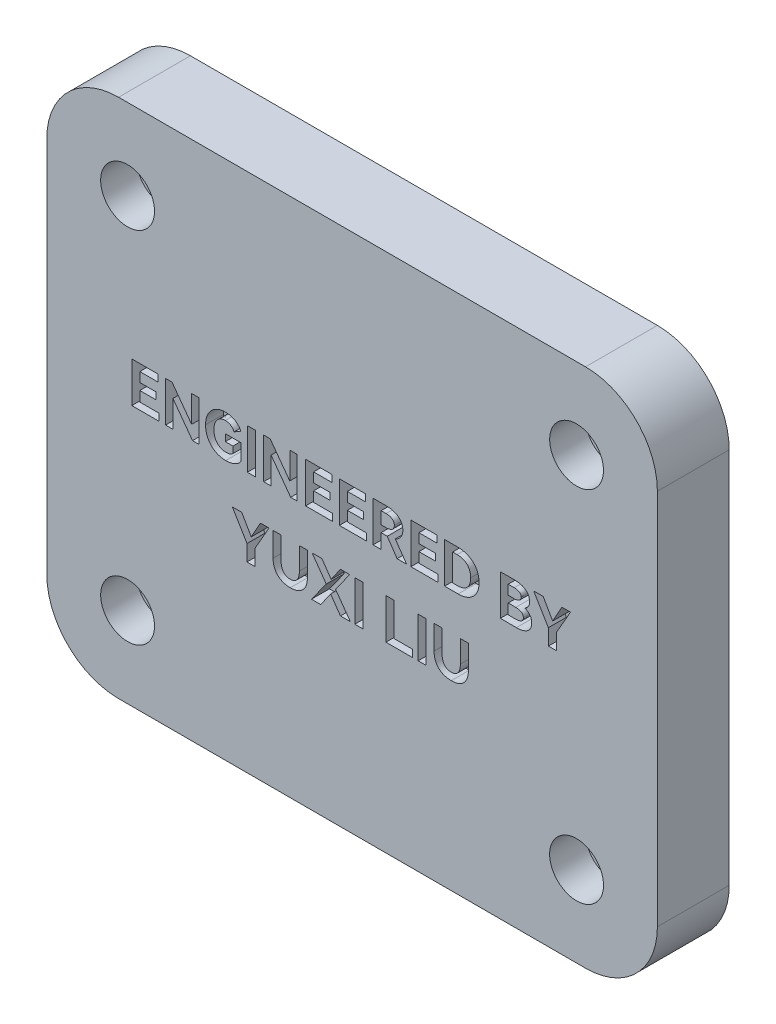
from build123d import *

# Parameters (mm, degrees)
SKETCH1_W           = 68
SKETCH1_H           = 58
BOSS_EXTRUDE1_DEPTH = 8
SKETCH2_R           = 1.6
CUT_EXTRUDE1_DEPTH  = 90.732937097
SKETCH3_R           = 3
CUT_EXTRUDE2_DEPTH  = 4
FILLET1_R           = 8
SKETCH4_W           = 0.89110672
SKETCH4_H           = 4.5
SKETCH4_W_2         = 0.891106719
CUT_EXTRUDE3_DEPTH  = 2


with BuildPart() as part:
    # Sketch1 → Boss-Extrude1 (new body)
    with BuildSketch(Plane.XY):
        with Locations((34, 29)):
            Rectangle(SKETCH1_W, SKETCH1_H)
    extrude(amount=BOSS_EXTRUDE1_DEPTH)

    # Sketch2 → Cut-Extrude1 (cut, through all)
    with BuildSketch(Plane.XY.offset(8)):
        with Locations((9, 49)):
            Circle(SKETCH2_R)
        with Locations(Location((59, 49, 0), (0, 0, 180))):
            Circle(SKETCH2_R)
        with Locations((59, 9)):
            Circle(SKETCH2_R)
        with Locations(Location((9, 9, 0), (0, 0, 180))):
            Circle(SKETCH2_R)
    extrude(amount=-CUT_EXTRUDE1_DEPTH, mode=Mode.SUBTRACT)

    # Sketch3 → Cut-Extrude2 (cut)
    with BuildSketch(Plane.XY.offset(8)):
        with Locations((9, 49)):
            Circle(SKETCH3_R)
        with Locations(Location((59, 49, 0), (0, 0, 180))):
            Circle(SKETCH3_R)
        with Locations((59, 9)):
            Circle(SKETCH3_R)
        with Locations(Location((9, 9, 0), (0, 0, 180))):
            Circle(SKETCH3_R)
    extrude(amount=-CUT_EXTRUDE2_DEPTH, mode=Mode.SUBTRACT)

    # Fillet1
    fillet1_edges = [part.edges().sort_by_distance(p)[0] for p in [
        (0, 58, 4),
        (68, 58, 4),
        (68, 0, 4),
        (0, 0, 4),
    ]]
    fillet(fillet1_edges, radius=FILLET1_R)

    # Sketch4 → Cut-Extrude3 (cut)
    with BuildSketch(Plane.XY.offset(8)):
        Polygon((12.190019763, 30.899604743), (10.364229249, 30.899604743), (10.364229249, 29.78083004), (12.472826087, 29.78083004), (12.472826087, 29), (9.47312253, 29), (9.47312253, 33.5), (12.405237154, 33.5), (12.405237154, 32.725395257), (10.364229249, 32.725395257), (10.364229249, 31.66798419), (12.190019763, 31.66798419), align=None)
        Polygon((13.949110672, 33.5), (16.131521739, 30.5243083), (16.131521739, 33.5), (16.961264822, 33.5), (16.961264822, 29), (16.235573123, 29), (14.047826087, 31.981027668), (14.047826087, 29), (13.229644269, 29), (13.229644269, 33.5), align=None)
        with BuildLine():
            Line((19.88270751, 30.727075099), (19.88270751, 31.495454545))
            Line((19.88270751, 31.495454545), (21.603557312, 31.495454545))
            Line((21.603557312, 31.495454545), (21.603557312, 29.663438735))
            add(Edge.make_bspline(
                [(21.603557312, 29.663438735), (21.585447013, 29.635459828), (21.549129791, 29.579352739), (21.483778407, 29.501847101), (21.411893283, 29.428092613), (21.332367461, 29.358267831), (21.244525097, 29.293515303), (21.14966514, 29.231717851), (21.04577871, 29.176459685), (20.936457937, 29.123641364), (20.82075793, 29.078241641), (20.702085581, 29.036753427), (20.579431167, 29.003536577), (20.454429545, 28.974424008), (20.325956051, 28.953875328), (20.195233451, 28.93716636), (20.061277186, 28.92868716), (19.971056671, 28.927026331), (19.925395257, 28.926185771)],
                knots=[0, 0, 0, 0, 0.837760271, 1.679990217, 2.544929539, 3.427533874, 4.338910806, 5.288456801, 6.272945858, 7.297089327, 8.341320962, 9.397943387, 10.45827055, 11.53659533, 12.625366476, 13.72988631, 14.851075027, 16, 16, 16, 16], degree=3))
            add(Edge.make_bspline(
                [(19.925395257, 28.926185771), (19.871409128, 28.926938661), (19.764725815, 28.928426467), (19.607045736, 28.943308769), (19.453811488, 28.966301087), (19.305057423, 28.997880887), (19.161195377, 29.040336188), (19.021700147, 29.090670993), (18.886659717, 29.150475949), (18.757238472, 29.219742062), (18.633660795, 29.297431544), (18.515757924, 29.381345642), (18.406339853, 29.474800779), (18.303104708, 29.573882698), (18.207380985, 29.680793635), (18.117984879, 29.794316297), (18.03776203, 29.916844827), (17.962681677, 30.044628298), (17.895738896, 30.178677193), (17.83950323, 30.318868234), (17.789638289, 30.463067224), (17.751500793, 30.612632974), (17.719587191, 30.766527349), (17.697892321, 30.925492423), (17.684083877, 31.089378631), (17.682448163, 31.200169384), (17.681620553, 31.256225296)],
                knots=[0, 0, 0, 0, 1.069561296, 2.113586308, 3.135478133, 4.139054237, 5.124324395, 6.105523171, 7.075971085, 8.048372863, 9.011682409, 9.96706009, 10.913291369, 11.860525061, 12.800627657, 13.754830667, 14.721001889, 15.700334832, 16.690775213, 17.686757511, 18.691776819, 19.711978727, 20.743098853, 21.804839495, 22.889332181, 24, 24, 24, 24], degree=3))
            add(Edge.make_bspline(
                [(17.681620553, 31.256225296), (17.682338975, 31.312882599), (17.683755609, 31.424603387), (17.699035365, 31.589284548), (17.720455292, 31.749232262), (17.752842427, 31.903885675), (17.793450865, 32.054112689), (17.8446463, 32.198732073), (17.902836931, 32.339200919), (17.971957173, 32.473275494), (18.047737827, 32.60194538), (18.131602606, 32.722934999), (18.221747917, 32.83657806), (18.318951419, 32.942646704), (18.422918612, 33.041359504), (18.53383921, 33.132497567), (18.651142017, 33.216118138), (18.774939167, 33.291566893), (18.903742404, 33.359283907), (19.037031444, 33.417688096), (19.173607483, 33.467735011), (19.31340981, 33.509044483), (19.457164658, 33.539563432), (19.603705448, 33.563163425), (19.754094276, 33.57660903), (19.855409131, 33.578295896), (19.906719368, 33.579150198)],
                knots=[0, 0, 0, 0, 1.131159616, 2.230498763, 3.300513467, 4.352457935, 5.383673727, 6.405979992, 7.414253141, 8.417735126, 9.415806143, 10.394568984, 11.355223429, 12.310609564, 13.265408537, 14.21597661, 15.175353225, 16.139940019, 17.109148635, 18.079351229, 19.043919855, 20.012477316, 20.987904129, 21.976802477, 22.975365016, 24, 24, 24, 24], degree=3))
            add(Edge.make_bspline(
                [(19.906719368, 33.579150198), (19.957741945, 33.578353381), (20.058186994, 33.576784736), (20.206014044, 33.56269204), (20.349116485, 33.542108163), (20.486521983, 33.51059684), (20.619186239, 33.471550943), (20.74663359, 33.423253317), (20.869459761, 33.366830499), (20.985491776, 33.300373735), (21.095462155, 33.229405951), (21.196029117, 33.151779924), (21.287574526, 33.06966007), (21.369329282, 32.982214095), (21.443108414, 32.890611067), (21.505887802, 32.793010224), (21.561401855, 32.691536584), (21.589480018, 32.619905248), (21.603557312, 32.583992095)],
                knots=[0, 0, 0, 0, 1.17016001, 2.303622935, 3.403856837, 4.484454622, 5.534447873, 6.5739282, 7.608391433, 8.631549699, 9.638764269, 10.608576157, 11.542682489, 12.456771363, 13.352074797, 14.236699835, 15.115950192, 16, 16, 16, 16], degree=3))
            Line((21.603557312, 32.583992095), (20.866304348, 32.159782609))
            add(Edge.make_bspline(
                [(20.866304348, 32.159782609), (20.842751165, 32.205375626), (20.796433867, 32.295034225), (20.70430848, 32.414031084), (20.59980661, 32.519548247), (20.480179247, 32.608417335), (20.34792225, 32.680633245), (20.202752338, 32.730888687), (20.046600568, 32.763410013), (19.93831196, 32.766497585), (19.88270751, 32.768083004)],
                knots=[0, 0, 0, 0, 1.004386668, 1.97512485, 2.936911434, 3.908797535, 4.886714011, 5.879478124, 6.91114628, 8, 8, 8, 8], degree=3))
            add(Edge.make_bspline(
                [(19.88270751, 32.768083004), (19.82353494, 32.765969904), (19.707391906, 32.761822343), (19.538117607, 32.72580976), (19.378094463, 32.667702216), (19.228365362, 32.586329145), (19.090822965, 32.483953111), (18.968540785, 32.360016776), (18.861419855, 32.216746268), (18.77083859, 32.054408901), (18.698831788, 31.875119675), (18.647768576, 31.680944394), (18.615912822, 31.473082126), (18.612059983, 31.329861795), (18.610079051, 31.256225296)],
                knots=[0, 0, 0, 0, 0.961041044, 1.886316962, 2.799516737, 3.720263746, 4.646492936, 5.576775119, 6.540591128, 7.546013389, 8.590342615, 9.672792099, 10.803469879, 12, 12, 12, 12], degree=3))
            add(Edge.make_bspline(
                [(18.610079051, 31.256225296), (18.610572534, 31.217969109), (18.611545305, 31.142557056), (18.619810833, 31.031256469), (18.632806593, 30.923738881), (18.6519616, 30.820287498), (18.674386898, 30.720186329), (18.704260011, 30.624568211), (18.737628755, 30.532073415), (18.777997727, 30.444496325), (18.82209492, 30.360779922), (18.871405886, 30.282203188), (18.924582366, 30.208287375), (18.982466557, 30.13949658), (19.04521297, 30.076553016), (19.110919789, 30.016989469), (19.18259776, 29.963952998), (19.257935712, 29.915047998), (19.337111424, 29.871258564), (19.419873723, 29.834019936), (19.505860488, 29.802778081), (19.594747428, 29.777208556), (19.68670906, 29.75629344), (19.781899753, 29.742672087), (19.88014108, 29.733112154), (19.94671496, 29.732319602), (19.980533597, 29.731916996)],
                knots=[0, 0, 0, 0, 1.190036652, 2.345845502, 3.470321741, 4.557532515, 5.617930628, 6.659430926, 7.671944366, 8.674877908, 9.656813806, 10.613877645, 11.558417442, 12.487751382, 13.407286364, 14.321766241, 15.244025914, 16.177742668, 17.114733078, 18.055844735, 18.998220842, 19.958478747, 20.931801387, 21.929590883, 22.948259987, 24, 24, 24, 24], degree=3))
            add(Edge.make_bspline(
                [(19.980533597, 29.731916996), (20.019402652, 29.732790956), (20.095270605, 29.734496826), (20.205904828, 29.747189297), (20.310095806, 29.767344326), (20.40796079, 29.795711916), (20.498879894, 29.833070159), (20.583053032, 29.878926817), (20.661599178, 29.932094373), (20.707905717, 29.974688356), (20.731126482, 29.996047431)],
                knots=[0, 0, 0, 0, 1.142493035, 2.230015796, 3.269182953, 4.259205674, 5.220542896, 6.152556429, 7.073585425, 8, 8, 8, 8], degree=3))
            Line((20.731126482, 29.996047431), (20.731126482, 30.727075099))
            Line((20.731126482, 30.727075099), (19.88270751, 30.727075099))
        make_face()
        with Locations((22.781916996, 31.25)):
            Rectangle(SKETCH4_W, SKETCH4_H)
        Polygon((24.877173913, 33.5), (27.05958498, 30.5243083), (27.05958498, 33.5), (27.889328063, 33.5), (27.889328063, 29), (27.163636364, 29), (24.975889328, 31.981027668), (24.975889328, 29), (24.15770751, 29), (24.15770751, 33.5), align=None)
        Polygon((31.541798419, 30.899604743), (29.716007905, 30.899604743), (29.716007905, 29.78083004), (31.824604743, 29.78083004), (31.824604743, 29), (28.824901186, 29), (28.824901186, 33.5), (31.75701581, 33.5), (31.75701581, 32.725395257), (29.716007905, 32.725395257), (29.716007905, 31.66798419), (31.541798419, 31.66798419), align=None)
        Polygon((35.298320158, 30.899604743), (33.472529644, 30.899604743), (33.472529644, 29.78083004), (35.581126482, 29.78083004), (35.581126482, 29), (32.581422925, 29), (32.581422925, 33.5), (35.513537549, 33.5), (35.513537549, 32.725395257), (33.472529644, 32.725395257), (33.472529644, 31.66798419), (35.298320158, 31.66798419), align=None)
        with BuildLine():
            Line((40.075790514, 29), (39.01215415, 29.006225296))
            Line((39.01215415, 29.006225296), (37.918280632, 30.623023715))
            Line((37.918280632, 30.623023715), (37.880928854, 30.623023715))
            Line((37.880928854, 30.623023715), (37.229051383, 30.623023715))
            Line((37.229051383, 30.623023715), (37.229051383, 29))
            Line((37.229051383, 29), (36.337944664, 29))
            Line((36.337944664, 29), (36.337944664, 33.5))
            Line((36.337944664, 33.5), (37.893379447, 33.5))
            add(Edge.make_bspline(
                [(37.893379447, 33.5), (37.936679816, 33.499606859), (38.022189633, 33.498830482), (38.148223538, 33.489103588), (38.270605298, 33.476411814), (38.388844446, 33.456982396), (38.502579159, 33.430682165), (38.612748583, 33.400952622), (38.718540022, 33.364053528), (38.820654082, 33.322794195), (38.917544489, 33.275375392), (39.009289511, 33.224136509), (39.094941597, 33.167666163), (39.175456042, 33.107464879), (39.249551041, 33.041139713), (39.31768814, 32.970193591), (39.380687969, 32.894914748), (39.437214416, 32.815064858), (39.488192475, 32.731495571), (39.5318286, 32.644278992), (39.567841286, 32.553813054), (39.599877896, 32.461632198), (39.622436751, 32.365559348), (39.639601857, 32.267013963), (39.649360955, 32.165017603), (39.650833536, 32.096066959), (39.651581028, 32.061067194)],
                knots=[0, 0, 0, 0, 1.2200695, 2.409400225, 3.560858665, 4.687156797, 5.783684645, 6.849872993, 7.90145962, 8.939416468, 9.952046838, 10.939655477, 11.899012187, 12.841448216, 13.770493987, 14.69818634, 15.611737774, 16.534412784, 17.452879405, 18.368300956, 19.279020852, 20.195813937, 21.115799313, 22.056678637, 23.013558267, 24, 24, 24, 24], degree=3))
            add(Edge.make_bspline(
                [(39.651581028, 32.061067194), (39.65092733, 32.025760747), (39.649633377, 31.955873799), (39.638478491, 31.853110903), (39.621840227, 31.753469143), (39.597677141, 31.657149432), (39.566658974, 31.563717426), (39.528331327, 31.473570348), (39.482732353, 31.387251201), (39.430971496, 31.304370934), (39.373565843, 31.225129524), (39.308996587, 31.151336334), (39.239497974, 31.081783069), (39.164828487, 31.016713468), (39.084173188, 30.956779037), (38.99775389, 30.901963695), (38.906318748, 30.850729656), (38.84193412, 30.821759294), (38.809387352, 30.807114625)],
                knots=[0, 0, 0, 0, 1.054662233, 2.087639297, 3.085144338, 4.071218206, 5.051586526, 6.023918905, 6.994636113, 7.965474552, 8.941672438, 9.914932327, 10.892013905, 11.877769453, 12.871610298, 13.891324161, 14.934053283, 16, 16, 16, 16], degree=3))
            Line((38.809387352, 30.807114625), (40.075790514, 29))
        make_face()
        with BuildLine():
            Line((37.229051383, 32.743181818), (37.229051383, 31.378952569))
            Line((37.229051383, 31.378952569), (37.788438735, 31.378952569))
            add(Edge.make_bspline(
                [(37.788438735, 31.378952569), (37.820471735, 31.379448719), (37.883454677, 31.380424243), (37.975831558, 31.38856891), (38.064386311, 31.401784315), (38.148381445, 31.420521454), (38.228659971, 31.443329035), (38.303863977, 31.47305816), (38.375903199, 31.506754044), (38.443100893, 31.546411806), (38.50428215, 31.591565494), (38.558908306, 31.641318134), (38.603260091, 31.698489924), (38.641327413, 31.759785685), (38.6697824, 31.827704016), (38.690241884, 31.900559244), (38.701645259, 31.979191825), (38.703491999, 32.033166104), (38.70444664, 32.061067194)],
                knots=[0, 0, 0, 0, 1.193392064, 2.34643473, 3.452436324, 4.527106391, 5.551260628, 6.558417018, 7.536691432, 8.512280761, 9.460022067, 10.366574529, 11.254978474, 12.147219442, 13.047898509, 13.988597637, 14.960239605, 16, 16, 16, 16], degree=3))
            add(Edge.make_bspline(
                [(38.70444664, 32.061067194), (38.703456022, 32.089256557), (38.701528799, 32.144098255), (38.690564314, 32.223723151), (38.669376188, 32.297119875), (38.642492053, 32.365630905), (38.605126099, 32.427469757), (38.560631857, 32.484014282), (38.507287555, 32.534188856), (38.446613864, 32.578386105), (38.379925703, 32.617202837), (38.308514443, 32.651078974), (38.23265121, 32.679631423), (38.152208078, 32.702340284), (38.067747483, 32.721637801), (37.978402463, 32.733217295), (37.884950046, 32.741829667), (37.821069379, 32.742724654), (37.788438735, 32.743181818)],
                knots=[0, 0, 0, 0, 1.047934578, 2.038730344, 2.976872647, 3.881028202, 4.765166578, 5.651155837, 6.547222764, 7.476984859, 8.434839262, 9.410454722, 10.41093961, 11.4428885, 12.51463761, 13.626944928, 14.787828634, 16, 16, 16, 16], degree=3))
            Line((37.788438735, 32.743181818), (37.229051383, 32.743181818))
        make_face(mode=Mode.SUBTRACT)
        Polygon((43.266699605, 30.899604743), (41.440909091, 30.899604743), (41.440909091, 29.78083004), (43.549505929, 29.78083004), (43.549505929, 29), (40.549802372, 29), (40.549802372, 33.5), (43.481916996, 33.5), (43.481916996, 32.725395257), (41.440909091, 32.725395257), (41.440909091, 31.66798419), (43.266699605, 31.66798419), align=None)
        with BuildLine():
            add(Edge.make_bspline(
                [(45.806620553, 33.5), (45.860893251, 33.499100468), (45.96809906, 33.497323608), (46.126632921, 33.484576792), (46.281277371, 33.464039749), (46.432260393, 33.435960293), (46.579373829, 33.398700329), (46.721799539, 33.351740501), (46.8612025, 33.29882251), (46.995959883, 33.236487667), (47.125465595, 33.166848738), (47.247827345, 33.088751083), (47.363929083, 33.004465251), (47.472721689, 32.911664394), (47.574064805, 32.810907206), (47.668893169, 32.702994195), (47.755883775, 32.587091182), (47.836096765, 32.464272003), (47.908335844, 32.334673006), (47.970235608, 32.198163622), (48.024020375, 32.056355081), (48.067969231, 31.908133062), (48.100137771, 31.753295405), (48.123993555, 31.592960711), (48.140065557, 31.426709117), (48.141344392, 31.313773753), (48.141996047, 31.256225296)],
                knots=[0, 0, 0, 0, 1.071711807, 2.116971104, 3.138652708, 4.151338474, 5.148077585, 6.132969995, 7.111438821, 8.091097786, 9.062906638, 10.012978114, 10.955571233, 11.894065112, 12.833745052, 13.775465164, 14.728525936, 15.69302499, 16.670460021, 17.655439419, 18.650320097, 19.6635641, 20.704963763, 21.770502017, 22.863915051, 24, 24, 24, 24], degree=3))
            add(Edge.make_bspline(
                [(48.141996047, 31.256225296), (48.141334489, 31.198677443), (48.140032827, 31.085447948), (48.124036295, 30.918895329), (48.100257585, 30.758536558), (48.067740684, 30.603776154), (48.023819452, 30.455003553), (47.970670579, 30.312040924), (47.908069632, 30.174951138), (47.836142842, 30.044617006), (47.755868771, 29.920945516), (47.668952019, 29.804091082), (47.574046414, 29.695663902), (47.473668421, 29.593342292), (47.36485799, 29.500360014), (47.249582492, 29.414467486), (47.127361003, 29.336194754), (46.998937976, 29.265024408), (46.864511703, 29.203303456), (46.726000824, 29.148535975), (46.5831459, 29.102383249), (46.435724, 29.065174378), (46.284660146, 29.035584197), (46.128989052, 29.015463357), (45.969285126, 29.002686087), (45.861190355, 29.000901113), (45.806620553, 29)],
                knots=[0, 0, 0, 0, 1.133225957, 2.229702705, 3.292559499, 4.325627437, 5.341923461, 6.345235728, 7.327736395, 8.307822006, 9.2747903, 10.230122054, 11.173872514, 12.111187721, 13.051118595, 13.990105764, 14.940929524, 15.907968343, 16.879861028, 17.852542807, 18.840511852, 19.834742639, 20.845976449, 21.870875749, 22.925147923, 24, 24, 24, 24], degree=3))
            Line((45.806620553, 29), (44.306324111, 29))
            Line((44.306324111, 29), (44.306324111, 33.5))
            Line((44.306324111, 33.5), (45.806620553, 33.5))
        make_face()
        with BuildLine():
            add(Edge.make_bspline(
                [(45.701679842, 29.76215415), (45.760420111, 29.763362485), (45.874624063, 29.765711754), (46.040652842, 29.783495305), (46.196364301, 29.813523295), (46.341444644, 29.856005423), (46.476302954, 29.910488885), (46.600245529, 29.977075627), (46.713563238, 30.056259535), (46.816252272, 30.147002167), (46.906916809, 30.249930313), (46.986909915, 30.362550351), (47.053844891, 30.486247217), (47.107928476, 30.620673914), (47.150643454, 30.765074253), (47.180628524, 30.919917969), (47.198389562, 31.084761436), (47.20075994, 31.198077756), (47.201976285, 31.256225296)],
                knots=[0, 0, 0, 0, 1.167953641, 2.270757765, 3.315899487, 4.317593627, 5.272176862, 6.203262519, 7.109264452, 8.015438977, 8.921613502, 9.831003729, 10.756905575, 11.711488811, 12.707529366, 13.74688605, 14.843829069, 16, 16, 16, 16], degree=3))
            add(Edge.make_bspline(
                [(47.201976285, 31.256225296), (47.200735568, 31.31347902), (47.19831858, 31.425012623), (47.180873874, 31.58761985), (47.149485706, 31.740170436), (47.107105163, 31.882920051), (47.052715334, 32.016220849), (46.984963533, 32.138949538), (46.905260796, 32.252207949), (46.813223425, 32.354745729), (46.710101902, 32.446520483), (46.596076973, 32.525881041), (46.472851067, 32.594394935), (46.338083342, 32.64822063), (46.193350345, 32.690836407), (46.038381124, 32.722044788), (45.873130989, 32.739527856), (45.759823071, 32.741942671), (45.701679842, 32.743181818)],
                knots=[0, 0, 0, 0, 1.143434422, 2.227477164, 3.260895609, 4.249907975, 5.197672452, 6.130431302, 7.043765239, 7.957808935, 8.876271422, 9.79444762, 10.72720647, 11.685929401, 12.686289439, 13.737115077, 14.838815157, 16, 16, 16, 16], degree=3))
            Line((45.701679842, 32.743181818), (45.19743083, 32.743181818))
            Line((45.19743083, 32.743181818), (45.19743083, 29.76215415))
            Line((45.19743083, 29.76215415), (45.701679842, 29.76215415))
        make_face(mode=Mode.SUBTRACT)
        with BuildLine():
            add(Edge.make_bspline(
                [(53.258300395, 31.336264822), (53.288399813, 31.325098941), (53.347605217, 31.30313571), (53.43209886, 31.264024956), (53.510547507, 31.220111123), (53.583553647, 31.173195685), (53.65086755, 31.122501917), (53.711329619, 31.066886533), (53.766953273, 31.008012533), (53.817025839, 30.944859945), (53.860221694, 30.877243284), (53.898398597, 30.806030149), (53.929679335, 30.730735092), (53.957191634, 30.65169336), (53.977148891, 30.568524886), (53.991230642, 30.481405273), (54.000582482, 30.390520284), (54.001374197, 30.328383706), (54.001778656, 30.296640316)],
                knots=[0, 0, 0, 0, 1.118818822, 2.200711033, 3.241553326, 4.250512751, 5.223973887, 6.174905597, 7.110668516, 8.045118163, 8.979567809, 9.904137332, 10.858040273, 11.818803306, 12.818832771, 13.834753529, 14.893851807, 16, 16, 16, 16], degree=3))
            add(Edge.make_bspline(
                [(54.001778656, 30.296640316), (54.000397586, 30.247360541), (53.997697913, 30.151029913), (53.977023036, 30.010501281), (53.94239391, 29.877966501), (53.893516687, 29.753509044), (53.829526907, 29.637987619), (53.752553732, 29.530251875), (53.661274432, 29.431306882), (53.556384754, 29.341172977), (53.43936453, 29.260388024), (53.309842963, 29.191056646), (53.170189522, 29.131113273), (53.018592108, 29.083718022), (52.856469041, 29.045004524), (52.6826876, 29.019230724), (52.49794741, 29.002795035), (52.37108489, 29.000949365), (52.30583004, 29)],
                knots=[0, 0, 0, 0, 0.980494461, 1.916641186, 2.81961074, 3.70153889, 4.570265206, 5.44127233, 6.330648019, 7.24253577, 8.188428989, 9.154619336, 10.161697494, 11.208416174, 12.311731756, 13.475717384, 14.701573284, 16, 16, 16, 16], degree=3))
            Line((52.30583004, 29), (50.51027668, 29))
            Line((50.51027668, 29), (50.51027668, 33.5))
            Line((50.51027668, 33.5), (52.139525692, 33.5))
            add(Edge.make_bspline(
                [(52.139525692, 33.5), (52.198250047, 33.498931025), (52.312934691, 33.49684339), (52.480601938, 33.481877051), (52.639734519, 33.455647801), (52.791252095, 33.421150111), (52.933545336, 33.373204535), (53.068158533, 33.317504001), (53.194090724, 33.250434322), (53.31095859, 33.173552012), (53.417478958, 33.087832107), (53.509422685, 32.991728233), (53.588732067, 32.888518229), (53.652134805, 32.775643838), (53.702624545, 32.655264332), (53.736536012, 32.525876394), (53.758855843, 32.388816598), (53.761296921, 32.294460399), (53.762549407, 32.246047431)],
                knots=[0, 0, 0, 0, 1.221040176, 2.384607852, 3.496273299, 4.57277662, 5.611723703, 6.614569644, 7.599003706, 8.573487563, 9.51982331, 10.435302592, 11.332800376, 12.218922678, 13.119821967, 14.039421554, 14.994052076, 16, 16, 16, 16], degree=3))
            add(Edge.make_bspline(
                [(53.762549407, 32.246047431), (53.761016491, 32.19586178), (53.758042152, 32.098485841), (53.734899532, 31.957242874), (53.694927719, 31.826845481), (53.639040783, 31.706964626), (53.568218897, 31.596804882), (53.4803377, 31.498019348), (53.376761306, 31.409339025), (53.298447096, 31.361029853), (53.258300395, 31.336264822)],
                knots=[0, 0, 0, 0, 1.099553501, 2.133479419, 3.126079771, 4.079461809, 5.023768473, 5.985789349, 6.967442668, 8, 8, 8, 8], degree=3))
        make_face()
        with BuildLine():
            Line((51.383596838, 32.725395257), (51.383596838, 31.661758893))
            Line((51.383596838, 31.661758893), (52.05326087, 31.661758893))
            add(Edge.make_bspline(
                [(52.05326087, 31.661758893), (52.110576367, 31.663648766), (52.220001673, 31.667256863), (52.374997984, 31.693874067), (52.511204984, 31.741374927), (52.61003846, 31.796873001), (52.677732113, 31.849812968), (52.721346418, 31.892409516), (52.758540857, 31.93810428), (52.788059546, 31.987699977), (52.811124673, 32.040336609), (52.828320237, 32.095748577), (52.838160564, 32.154394908), (52.839586425, 32.194430193), (52.840316206, 32.214920949)],
                knots=[0, 0, 0, 0, 1.91479465, 3.655677756, 5.231467064, 6.713138413, 7.418562491, 8.097985844, 8.746148474, 9.381468873, 10.020100863, 10.662409344, 11.315397821, 12, 12, 12, 12], degree=3))
            add(Edge.make_bspline(
                [(52.840316206, 32.214920949), (52.839609676, 32.234827169), (52.838229947, 32.273700582), (52.828137787, 32.330118707), (52.812401669, 32.383271094), (52.788900912, 32.432504916), (52.758988481, 32.478251023), (52.72364713, 32.521467613), (52.680150261, 32.559553554), (52.613218464, 32.606964793), (52.51406512, 32.655569985), (52.377877906, 32.697085777), (52.221922913, 32.721615589), (52.111455725, 32.724091127), (52.05326087, 32.725395257)],
                knots=[0, 0, 0, 0, 0.680418715, 1.328740338, 1.954065901, 2.570786416, 3.186589749, 3.81999806, 4.473293787, 5.156801734, 6.621163746, 8.224356342, 10.010965592, 12, 12, 12, 12], degree=3))
            Line((52.05326087, 32.725395257), (51.383596838, 32.725395257))
        make_face(mode=Mode.SUBTRACT)
        with BuildLine():
            add(Edge.make_bspline(
                [(52.23201581, 29.774604743), (52.264928365, 29.775252147), (52.328736398, 29.776507278), (52.421430766, 29.782301046), (52.508255379, 29.793683363), (52.589138573, 29.811035525), (52.664594795, 29.830787898), (52.73408766, 29.855812537), (52.797333126, 29.886262023), (52.855385079, 29.920702506), (52.906994655, 29.959781305), (52.951969596, 30.002612145), (52.989810524, 30.049602247), (53.021150729, 30.099884416), (53.044340957, 30.155020272), (53.062444572, 30.212939456), (53.072030518, 30.275577334), (53.073469053, 30.318252124), (53.074209486, 30.340217391)],
                knots=[0, 0, 0, 0, 1.382825555, 2.680903359, 3.899677623, 5.05736951, 6.153970811, 7.174309096, 8.154648833, 9.098641606, 10.00525847, 10.868410623, 11.700830498, 12.533809106, 13.348147117, 14.206976277, 15.077107487, 16, 16, 16, 16], degree=3))
            add(Edge.make_bspline(
                [(53.074209486, 30.340217391), (53.073446074, 30.362178709), (53.071952719, 30.405138525), (53.062593861, 30.468119149), (53.044154117, 30.526528134), (53.021179092, 30.582299449), (52.989866376, 30.633517491), (52.951706236, 30.681347624), (52.907400484, 30.726070394), (52.855116871, 30.765779051), (52.797660517, 30.802311226), (52.733893575, 30.833741766), (52.663812876, 30.858958934), (52.588301263, 30.881628234), (52.506138088, 30.898275699), (52.417838419, 30.909438588), (52.323735015, 30.916665403), (52.259005778, 30.917732871), (52.225790514, 30.918280632)],
                knots=[0, 0, 0, 0, 0.912319421, 1.784641302, 2.63363131, 3.449950279, 4.283901569, 5.116397762, 5.986893518, 6.890617376, 7.836698498, 8.811187296, 9.835639131, 10.926367186, 12.082849546, 13.312068463, 14.620710532, 16, 16, 16, 16], degree=3))
            Line((52.225790514, 30.918280632), (51.383596838, 30.918280632))
            Line((51.383596838, 30.918280632), (51.383596838, 29.774604743))
            Line((51.383596838, 29.774604743), (52.23201581, 29.774604743))
        make_face(mode=Mode.SUBTRACT)
        Polygon((56.33715415, 31.655533597), (57.358102767, 33.5), (58.323023715, 33.5), (56.75513834, 30.770652174), (56.75513834, 29), (55.864031621, 29), (55.864031621, 30.77687747), (54.228557312, 33.5), (55.279743083, 33.5), align=None)
        Polygon((22.769565217, 22.983992095), (23.790513834, 24.828458498), (24.755434783, 24.828458498), (23.187549407, 22.099110672), (23.187549407, 20.328458498), (22.296442688, 20.328458498), (22.296442688, 22.105335968), (20.660968379, 24.828458498), (21.71215415, 24.828458498), align=None)
        with BuildLine():
            Line((28.129545455, 24.828458498), (29.020652174, 24.828458498))
            Line((29.020652174, 24.828458498), (29.020652174, 22.148023715))
            add(Edge.make_bspline(
                [(29.020652174, 22.148023715), (29.020000269, 22.100571553), (29.018719201, 22.007322545), (29.007661092, 21.869573501), (28.990171726, 21.736523943), (28.965361979, 21.60818027), (28.933047961, 21.484684296), (28.894257084, 21.365720187), (28.84780143, 21.251342371), (28.794293595, 21.142200912), (28.735427728, 21.037739754), (28.667685078, 20.940944845), (28.596051711, 20.8484879), (28.516493506, 20.76323032), (28.430920437, 20.683843042), (28.338945286, 20.61043368), (28.240151311, 20.544152361), (28.135680555, 20.483374929), (28.025923282, 20.429091369), (27.910245824, 20.383163177), (27.790300633, 20.342461799), (27.664545089, 20.311365623), (27.534452074, 20.284762215), (27.399178666, 20.267684969), (27.259081765, 20.256560754), (27.164054139, 20.255290484), (27.115711462, 20.254644269)],
                knots=[0, 0, 0, 0, 1.123185627, 2.207190164, 3.269163521, 4.298641387, 5.299496827, 6.289268694, 7.258831827, 8.21923409, 9.165403558, 10.093919452, 11.013481476, 11.932159396, 12.850837316, 13.77475387, 14.71486612, 15.664542481, 16.634334162, 17.610402549, 18.609041253, 19.630281915, 20.674885131, 21.750772402, 22.855767676, 24, 24, 24, 24], degree=3))
            add(Edge.make_bspline(
                [(27.115711462, 20.254644269), (27.066776428, 20.255293565), (26.970565598, 20.256570142), (26.828982325, 20.267633239), (26.69252681, 20.284759385), (26.561557796, 20.31139748), (26.435141186, 20.342279969), (26.314742914, 20.383385954), (26.198588907, 20.428860356), (26.08863855, 20.483403005), (25.984155546, 20.544146038), (25.885358271, 20.610431467), (25.793407808, 20.683857744), (25.707740085, 20.763173986), (25.628410676, 20.84883384), (25.555455755, 20.940315157), (25.48923796, 21.038344369), (25.428848381, 21.141865581), (25.375781379, 21.251420352), (25.328882596, 21.365526602), (25.291540871, 21.484873382), (25.258861968, 21.608152362), (25.234160224, 21.736531768), (25.216640679, 21.869571341), (25.205590815, 22.007323113), (25.20430861, 22.100571745), (25.203656126, 22.148023715)],
                knots=[0, 0, 0, 0, 1.155523229, 2.271866189, 3.352149668, 4.401149285, 5.42675874, 6.423034746, 7.403290734, 8.370787966, 9.31821747, 10.25610549, 11.177836133, 12.094340535, 13.010844938, 13.93257558, 14.854944135, 15.802373639, 16.760503668, 17.727772893, 18.713041353, 19.711528851, 20.738571055, 21.798031869, 22.879471739, 24, 24, 24, 24], degree=3))
            Line((25.203656126, 22.148023715), (25.203656126, 24.828458498))
            Line((25.203656126, 24.828458498), (26.094762846, 24.828458498))
            Line((26.094762846, 24.828458498), (26.094762846, 22.363241107))
            add(Edge.make_bspline(
                [(26.094762846, 22.363241107), (26.095627842, 22.310744537), (26.097306634, 22.208858813), (26.109880877, 22.061240363), (26.129891273, 21.923551267), (26.158793221, 21.796053742), (26.197390277, 21.679376991), (26.242188553, 21.572430393), (26.296911103, 21.47634396), (26.360101482, 21.39083301), (26.430925955, 21.315354681), (26.508756527, 21.250313907), (26.592766669, 21.194243542), (26.684703366, 21.150064616), (26.782518148, 21.114099882), (26.887591898, 21.089260804), (26.999421901, 21.075272488), (27.076245182, 21.073068837), (27.115711462, 21.071936759)],
                knots=[0, 0, 0, 0, 1.344225643, 2.608882906, 3.79093548, 4.905046283, 5.951733108, 6.93458622, 7.869601029, 8.776042514, 9.651434434, 10.513592479, 11.368433444, 12.230791999, 13.119350411, 14.032632583, 14.989308017, 16, 16, 16, 16], degree=3))
            add(Edge.make_bspline(
                [(27.115711462, 21.071936759), (27.154585464, 21.073076486), (27.230522432, 21.075302844), (27.341162338, 21.089287627), (27.44512634, 21.11393034), (27.54165036, 21.150235517), (27.632574889, 21.19450825), (27.716402201, 21.250003135), (27.793402473, 21.315682799), (27.864244806, 21.390787379), (27.927386526, 21.476356779), (27.982122803, 21.572426723), (28.026917129, 21.679378066), (28.065515342, 21.796053426), (28.09441695, 21.923551359), (28.114427446, 22.061240336), (28.12700166, 22.208858821), (28.128680456, 22.31074454), (28.129545455, 22.363241107)],
                knots=[0, 0, 0, 0, 0.99908038, 1.951616292, 2.860752761, 3.738180462, 4.596784729, 5.45467889, 6.31409399, 7.192612506, 8.102291486, 9.040645843, 10.027009366, 11.077434593, 12.195524613, 13.381799069, 14.650973249, 16, 16, 16, 16], degree=3))
            Line((28.129545455, 22.363241107), (28.129545455, 24.828458498))
        make_face()
        Polygon((33.737648221, 24.828458498), (32.157312253, 22.633596838), (33.811462451, 20.328458498), (32.704249012, 20.328458498), (31.610375494, 21.907905138), (30.51027668, 20.328458498), (29.477766798, 20.328458498), (31.124802372, 22.614920949), (29.551581028, 24.828458498), (30.639229249, 24.828458498), (31.67173913, 23.340612648), (32.704249012, 24.828458498), align=None)
        with Locations((34.747924901, 22.578458498)):
            Rectangle(SKETCH4_W_2, SKETCH4_H)
        Polygon((37.7743083, 24.828458498), (38.66541502, 24.828458498), (38.66541502, 21.127964427), (40.712648221, 21.127964427), (40.712648221, 20.328458498), (37.7743083, 20.328458498), align=None)
        with Locations((41.805632411, 22.578458498)):
            Rectangle(SKETCH4_W, SKETCH4_H)
        with BuildLine():
            Line((46.058399209, 24.828458498), (46.949505929, 24.828458498))
            Line((46.949505929, 24.828458498), (46.949505929, 22.148023715))
            add(Edge.make_bspline(
                [(46.949505929, 22.148023715), (46.948854024, 22.100571553), (46.947572956, 22.007322545), (46.936514847, 21.869573501), (46.919025481, 21.736523943), (46.894215734, 21.60818027), (46.861901716, 21.484684296), (46.823110839, 21.365720187), (46.776655185, 21.251342371), (46.72314735, 21.142200912), (46.664281483, 21.037739754), (46.596538833, 20.940944845), (46.524905466, 20.8484879), (46.44534726, 20.76323032), (46.359774192, 20.683843042), (46.267799041, 20.61043368), (46.169005066, 20.544152361), (46.06453431, 20.483374929), (45.954777036, 20.429091369), (45.839099579, 20.383163177), (45.719154388, 20.342461799), (45.593398844, 20.311365623), (45.463305829, 20.284762215), (45.328032421, 20.267684969), (45.18793552, 20.256560754), (45.092907894, 20.255290484), (45.044565217, 20.254644269)],
                knots=[0, 0, 0, 0, 1.123185627, 2.207190164, 3.269163521, 4.298641387, 5.299496827, 6.289268694, 7.258831827, 8.21923409, 9.165403558, 10.093919452, 11.013481476, 11.932159396, 12.850837316, 13.77475387, 14.71486612, 15.664542481, 16.634334162, 17.610402549, 18.609041253, 19.630281915, 20.674885131, 21.750772402, 22.855767676, 24, 24, 24, 24], degree=3))
            add(Edge.make_bspline(
                [(45.044565217, 20.254644269), (44.995630183, 20.255293565), (44.899419353, 20.256570142), (44.75783608, 20.267633239), (44.621380565, 20.284759385), (44.49041155, 20.31139748), (44.363994941, 20.342279969), (44.243596669, 20.383385954), (44.127442662, 20.428860356), (44.017492305, 20.483403005), (43.913009301, 20.544146038), (43.814212026, 20.610431467), (43.722261563, 20.683857744), (43.63659384, 20.763173986), (43.557264431, 20.84883384), (43.484309509, 20.940315157), (43.418091715, 21.038344369), (43.357702136, 21.141865581), (43.304635134, 21.251420352), (43.257736351, 21.365526602), (43.220394626, 21.484873382), (43.187715723, 21.608152362), (43.163013979, 21.736531768), (43.145494434, 21.869571341), (43.13444457, 22.007323113), (43.133162365, 22.100571745), (43.132509881, 22.148023715)],
                knots=[0, 0, 0, 0, 1.155523229, 2.271866189, 3.352149668, 4.401149285, 5.42675874, 6.423034746, 7.403290734, 8.370787966, 9.31821747, 10.25610549, 11.177836133, 12.094340535, 13.010844938, 13.93257558, 14.854944135, 15.802373639, 16.760503668, 17.727772893, 18.713041353, 19.711528851, 20.738571055, 21.798031869, 22.879471739, 24, 24, 24, 24], degree=3))
            Line((43.132509881, 22.148023715), (43.132509881, 24.828458498))
            Line((43.132509881, 24.828458498), (44.023616601, 24.828458498))
            Line((44.023616601, 24.828458498), (44.023616601, 22.363241107))
            add(Edge.make_bspline(
                [(44.023616601, 22.363241107), (44.024481597, 22.310744537), (44.026160389, 22.208858813), (44.038734632, 22.061240363), (44.058745028, 21.923551267), (44.087646976, 21.796053742), (44.126244032, 21.679376991), (44.171042308, 21.572430393), (44.225764858, 21.47634396), (44.288955237, 21.39083301), (44.35977971, 21.315354681), (44.437610282, 21.250313907), (44.521620424, 21.194243542), (44.613557121, 21.150064616), (44.711371903, 21.114099882), (44.816445653, 21.089260804), (44.928275656, 21.075272488), (45.005098937, 21.073068837), (45.044565217, 21.071936759)],
                knots=[0, 0, 0, 0, 1.344225643, 2.608882906, 3.79093548, 4.905046283, 5.951733108, 6.93458622, 7.869601029, 8.776042514, 9.651434434, 10.513592479, 11.368433444, 12.230791999, 13.119350411, 14.032632583, 14.989308017, 16, 16, 16, 16], degree=3))
            add(Edge.make_bspline(
                [(45.044565217, 21.071936759), (45.083439219, 21.073076486), (45.159376187, 21.075302844), (45.270016093, 21.089287627), (45.373980095, 21.11393034), (45.470504115, 21.150235517), (45.561428644, 21.19450825), (45.645255956, 21.250003135), (45.722256228, 21.315682799), (45.793098561, 21.390787379), (45.856240281, 21.476356779), (45.910976558, 21.572426723), (45.955770884, 21.679378066), (45.994369097, 21.796053426), (46.023270705, 21.923551359), (46.043281201, 22.061240336), (46.055855415, 22.208858821), (46.057534211, 22.31074454), (46.058399209, 22.363241107)],
                knots=[0, 0, 0, 0, 0.99908038, 1.951616292, 2.860752761, 3.738180462, 4.596784729, 5.45467889, 6.31409399, 7.192612506, 8.102291486, 9.040645843, 10.027009366, 11.077434593, 12.195524613, 13.381799069, 14.650973249, 16, 16, 16, 16], degree=3))
            Line((46.058399209, 22.363241107), (46.058399209, 24.828458498))
        make_face()
    extrude(amount=-CUT_EXTRUDE3_DEPTH, mode=Mode.SUBTRACT)


solid = part.part
